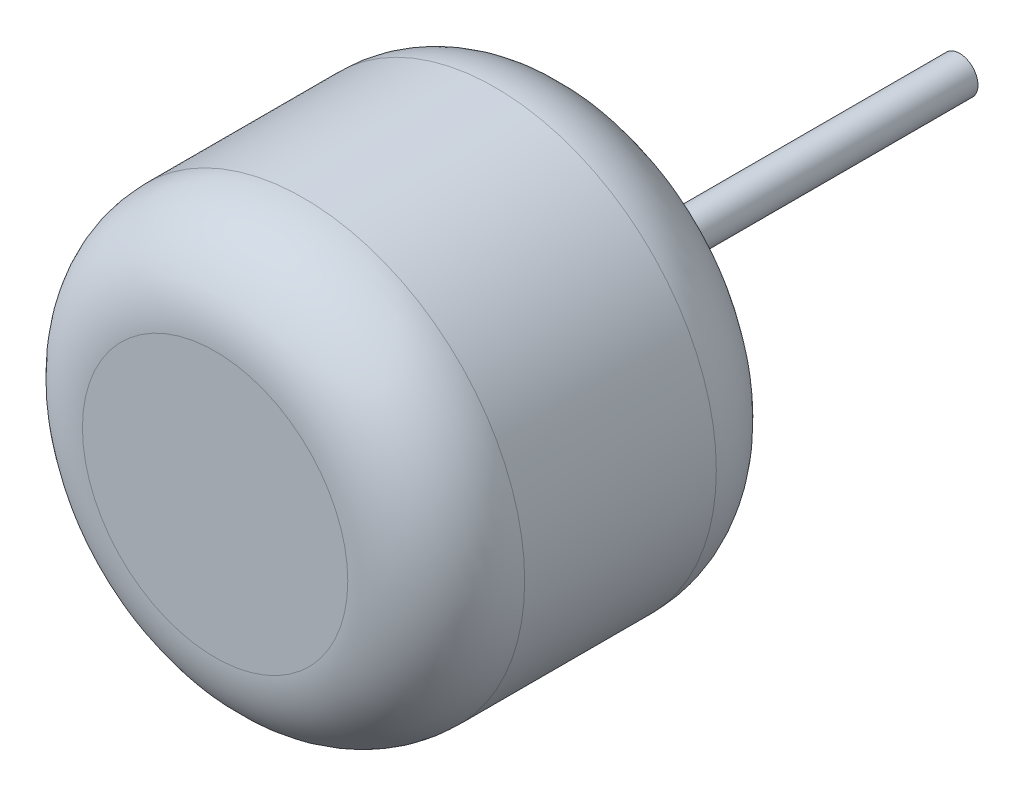
from build123d import *

# Parameters (mm, degrees)
SKETCH2_R           = 150
BOSS_EXTRUDE1_DEPTH = 250
SKETCH3_R           = 12.5
BOSS_EXTRUDE2_DEPTH = 255
FILLET1_R           = 60


with BuildPart() as part:
    # Sketch2 → Boss-Extrude1 (new body)
    with BuildSketch(Plane.XY):
        Circle(SKETCH2_R)
    extrude(amount=BOSS_EXTRUDE1_DEPTH)

    # Sketch3 → Boss-Extrude2 (add)
    with BuildSketch(Plane(origin=(0, 0, 0), x_dir=(-1, 0, 0), z_dir=(0, 0, -1))):
        Circle(SKETCH3_R)
    extrude(amount=BOSS_EXTRUDE2_DEPTH)

    # Fillet1
    fillet1_edges = [part.edges().sort_by_distance(p)[0] for p in [
        (-150, 0, 0),
        (-150, 0, 250),
    ]]
    fillet(fillet1_edges, radius=FILLET1_R)


solid = part.part
